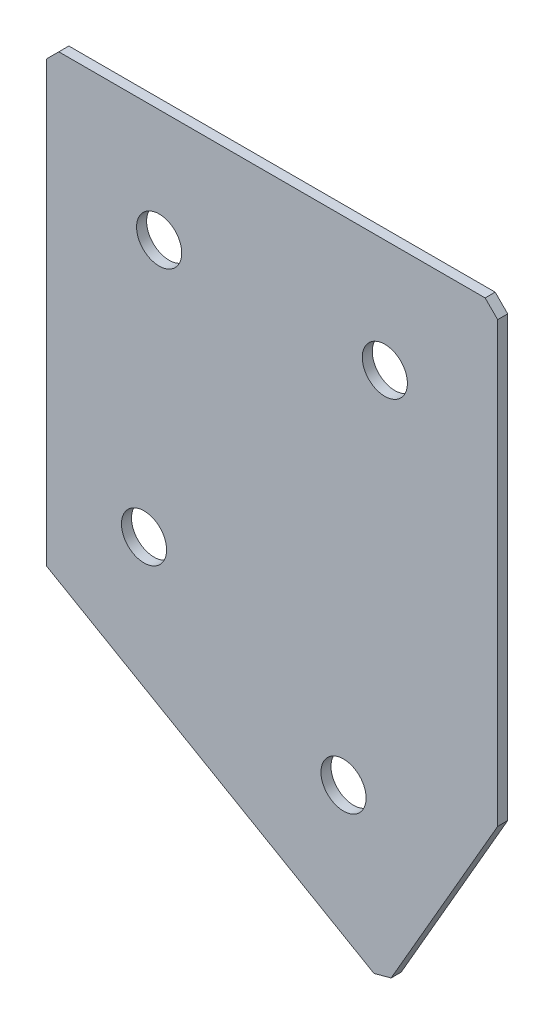
from build123d import *

# Parameters (mm, degrees)
EXTRUDE_1_DEPTH   = 2
HOLE_WIZARD_M81_D = 9
CHAMFER_1_SIZE    = 2.5


with BuildPart() as part:
    # Эскиз3 → Бобышка-Вытянуть1 (new body)
    with BuildSketch(Plane(origin=(0, 0, 0), x_dir=(1, 0, 0), z_dir=(0, 0, -1))):
        Polygon((0, 0), (90, 0), (90, 90), (67.5, 128.97114317), (0, 90), align=None)
    extrude(amount=EXTRUDE_1_DEPTH)

    # Отверстие с зазором M81 (through all)
    with Locations(Plane(origin=(0, 0, -2), x_dir=(1, 0, 0), z_dir=(0, 0, -1))):
        with Locations((22.5, 22.5), (67.5, 22.5), (19.485571585, 75.269237886), (59.264428415, 98.235571585)):
            Hole(HOLE_WIZARD_M81_D / 2)

    # Фаска1
    chamfer_1_edges = [part.edges().sort_by_distance(p)[0] for p in [
        (67.5, -128.97114317, -1),
        (90, 0, -1),
        (0, 0, -1),
    ]]
    chamfer(chamfer_1_edges, length=CHAMFER_1_SIZE)


solid = part.part
